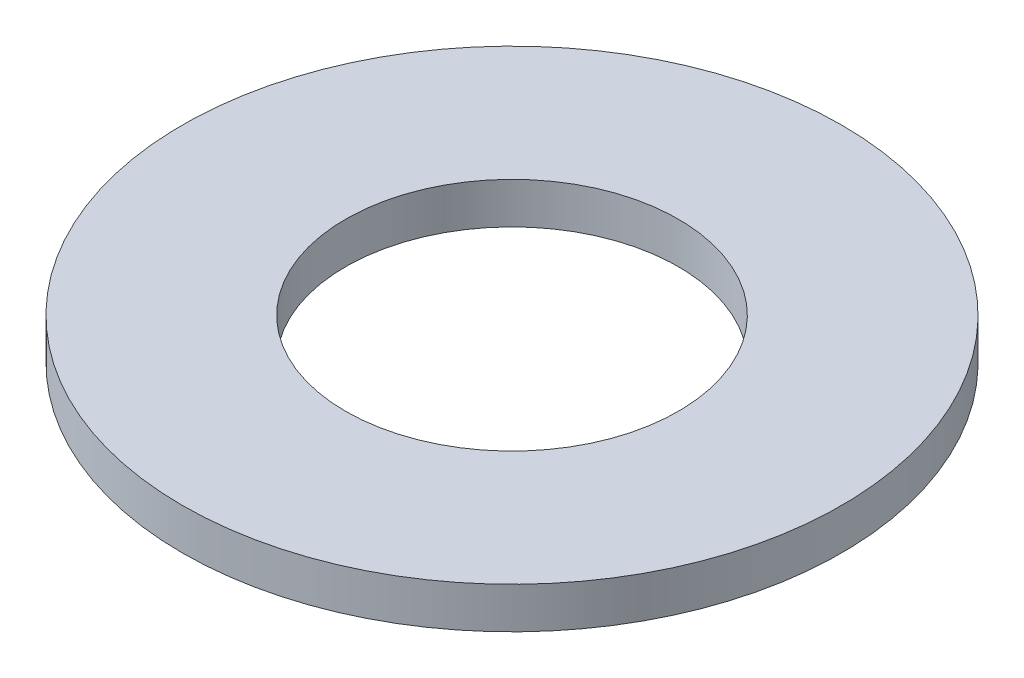
from build123d import *

# Parameters (mm, degrees)
SKETCH1_R           = 12.7
SKETCH1_R_2         = 6.4135
BOSS_EXTRUDE1_DEPTH = 0.79375


with BuildPart() as part:
    # Sketch1 → Boss-Extrude1 (new body, symmetric)
    with BuildSketch(Plane(origin=(0, 0, 0), x_dir=(1, 0, 0), z_dir=(0, 1, 0))):
        Circle(SKETCH1_R)
        Circle(SKETCH1_R_2, mode=Mode.SUBTRACT)
    extrude(amount=BOSS_EXTRUDE1_DEPTH, both=True)


solid = part.part
